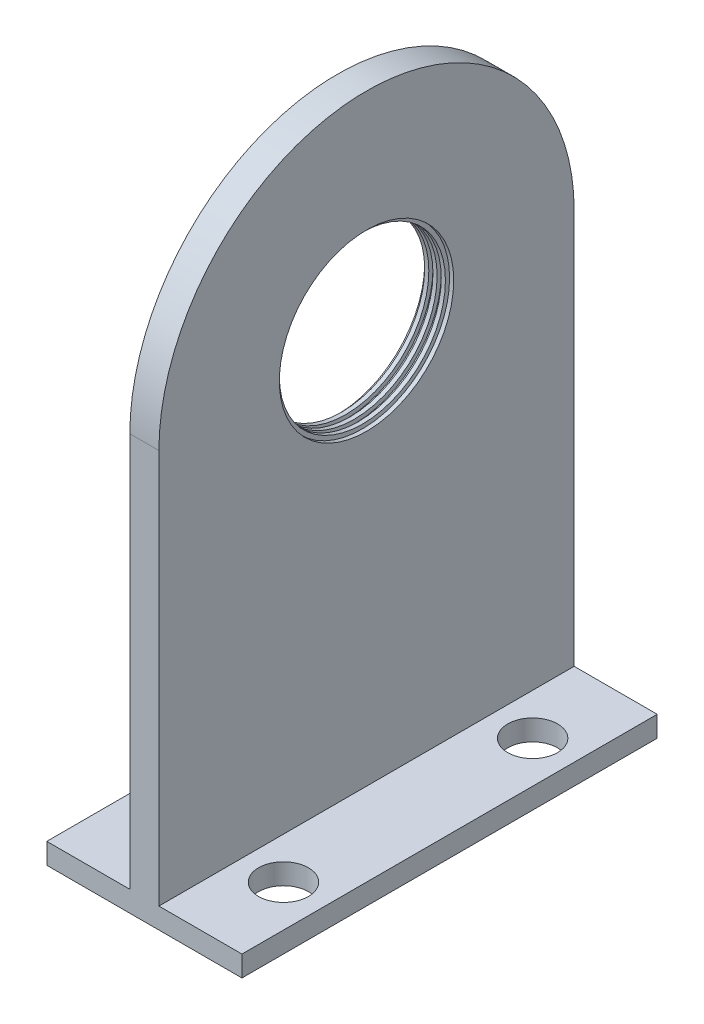
from build123d import *

# Parameters (mm, degrees)
SKETCH1_R                = 2
BOSS_EXTRUDE1_DEPTH      = 0.7
SKETCH2_R                = 2.1
CUT_EXTRUDE1_DEPTH       = 0.1
SKETCH3_R                = 2.1
CUT_EXTRUDE2_DEPTH       = 0.1
SKETCH4_R                = 2.1
CUT_EXTRUDE3_DEPTH       = 0.1
SKETCH5_R                = 2.1
CUT_EXTRUDE4_DEPTH       = 0.1
SKETCH6_W                = 10
SKETCH6_H                = 0.5
BOSS_EXTRUDE2_DEPTH      = 2.7
BOSS_EXTRUDE2_DEPTH_BACK = 2
SKETCH7_R                = 0.6
CUT_EXTRUDE5_DEPTH       = 2.7
SKETCH8_R                = 0.6
CUT_EXTRUDE6_DEPTH       = 2.7


with BuildPart() as part:
    # Sketch1 → Boss-Extrude1 (new body)
    with BuildSketch(Plane(origin=(0, 0, 0), x_dir=(0, 0, -1), z_dir=(1, 0, 0))):
        with BuildLine():
            Line((-5, 0), (5, 0))
            Line((5, 0), (5, 10))
            ThreePointArc((5, 10), (0, 15), (-5, 10))
            Line((-5, 10), (-5, 0))
        make_face()
        with Locations((0, 10)):
            Circle(SKETCH1_R, mode=Mode.SUBTRACT)
    extrude(amount=BOSS_EXTRUDE1_DEPTH)

    # Sketch2 → Cut-Extrude1 (cut)
    with BuildSketch(Plane(origin=(0, 0, 0), x_dir=(0, 0, -1), z_dir=(1, 0, 0))):
        with Locations((0, 10)):
            Circle(SKETCH2_R)
    extrude(amount=CUT_EXTRUDE1_DEPTH, mode=Mode.SUBTRACT)

    # Sketch3 → Cut-Extrude2 (cut)
    with BuildSketch(Plane(origin=(0.7, 0, 0), x_dir=(0, 0, -1), z_dir=(1, 0, 0))):
        with Locations((0, 10)):
            Circle(SKETCH3_R)
    extrude(amount=-CUT_EXTRUDE2_DEPTH, mode=Mode.SUBTRACT)

    # Sketch4 → Cut-Extrude3 (cut)
    with BuildSketch(Plane(origin=(0.5, 0, 0), x_dir=(0, 0, -1), z_dir=(1, 0, 0))):
        with Locations((0, 10)):
            Circle(SKETCH4_R)
    extrude(amount=-CUT_EXTRUDE3_DEPTH, mode=Mode.SUBTRACT)

    # Sketch5 → Cut-Extrude4 (cut)
    with BuildSketch(Plane(origin=(0.3, 0, 0), x_dir=(0, 0, -1), z_dir=(1, 0, 0))):
        with Locations((0, 10)):
            Circle(SKETCH5_R)
    extrude(amount=-CUT_EXTRUDE4_DEPTH, mode=Mode.SUBTRACT)

    # Sketch6 → Boss-Extrude2 (add, two sides)
    with BuildSketch(Plane(origin=(0, 0, 0), x_dir=(0, 0, -1), z_dir=(1, 0, 0))) as boss_extrude2_sk:
        with Locations((0, 0.25)):
            Rectangle(SKETCH6_W, SKETCH6_H)
    extrude(amount=BOSS_EXTRUDE2_DEPTH)
    extrude(boss_extrude2_sk.sketch, amount=-BOSS_EXTRUDE2_DEPTH_BACK)

    # Sketch7 → Cut-Extrude5 (cut)
    with BuildSketch(Plane(origin=(0, 0.5, 0), x_dir=(1, 0, 0), z_dir=(0, 1, 0))):
        with Locations((1.7, 3)):
            Circle(SKETCH7_R)
        with Locations((1.7, -3)):
            Circle(SKETCH7_R)
    extrude(amount=-CUT_EXTRUDE5_DEPTH, mode=Mode.SUBTRACT)

    # Sketch8 → Cut-Extrude6 (cut)
    with BuildSketch(Plane(origin=(0, 0.5, 0), x_dir=(1, 0, 0), z_dir=(0, 1, 0))):
        with Locations((-1, 3)):
            Circle(SKETCH8_R)
        with Locations((-1, -3)):
            Circle(SKETCH8_R)
    extrude(amount=-CUT_EXTRUDE6_DEPTH, mode=Mode.SUBTRACT)


solid = part.part
